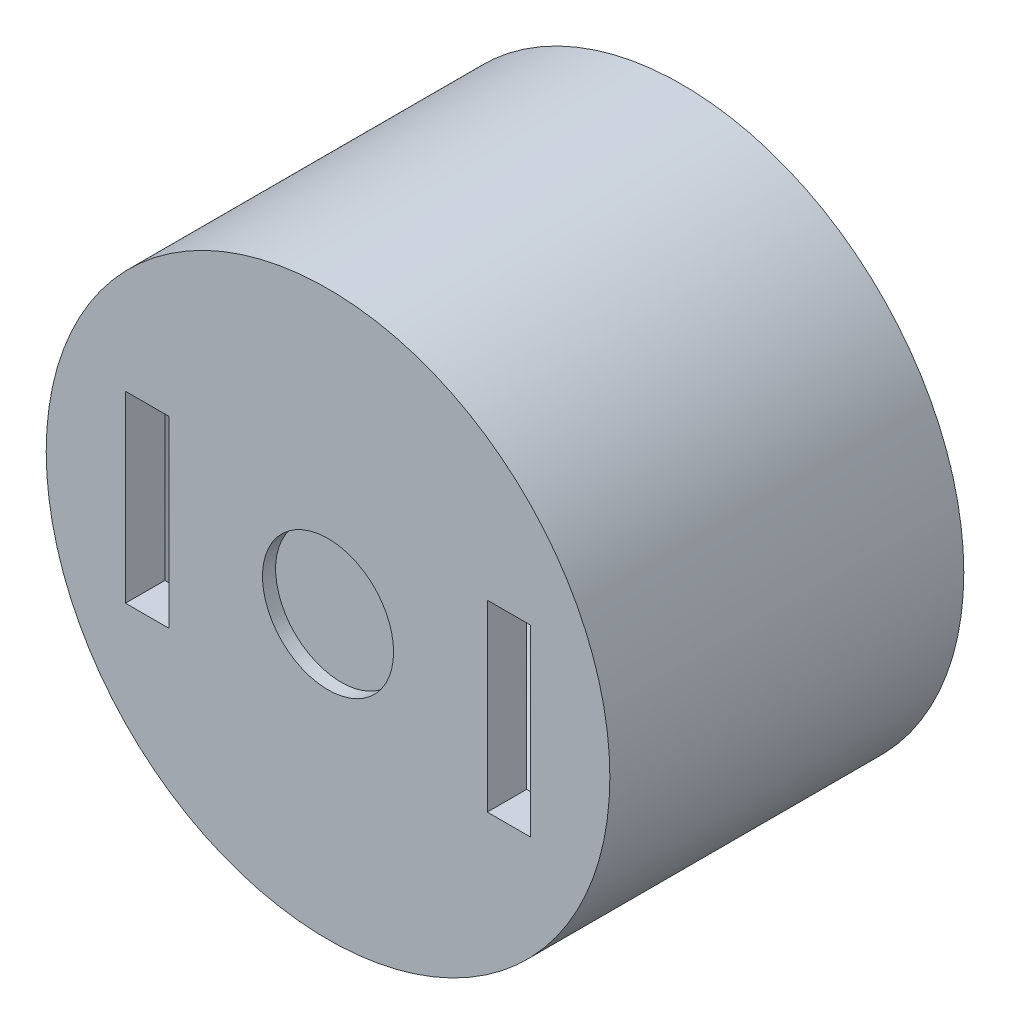
from build123d import *

# Parameters (mm, degrees)
SKETCH1_R           = 21.5
BOSS_EXTRUDE1_DEPTH = 27
SKETCH2_R           = 18.75
CUT_EXTRUDE2_DEPTH  = 24
SKETCH4_W           = 3.3
SKETCH4_H           = 14
CUT_EXTRUDE6_DEPTH  = 32
SKETCH7_R           = 5
CUT_EXTRUDE8_DEPTH  = 1


with BuildPart() as part:
    # Sketch1 → Boss-Extrude1 (new body)
    with BuildSketch(Plane.XY):
        Circle(SKETCH1_R)
    extrude(amount=BOSS_EXTRUDE1_DEPTH)

    # Sketch2 → Cut-Extrude2 (cut)
    with BuildSketch(Plane.XY):
        Circle(SKETCH2_R)
    extrude(amount=CUT_EXTRUDE2_DEPTH, mode=Mode.SUBTRACT)

    # Sketch4 → Cut-Extrude6 (cut)
    with BuildSketch(Plane.XY):
        with Locations((13.8, 0)):
            Rectangle(SKETCH4_W, SKETCH4_H)
        with Locations((-13.8, 0)):
            Rectangle(SKETCH4_W, SKETCH4_H)
    extrude(amount=CUT_EXTRUDE6_DEPTH, mode=Mode.SUBTRACT)

    # Sketch7 → Cut-Extrude8 (cut)
    with BuildSketch(Plane.XY.offset(27)):
        Circle(SKETCH7_R)
    extrude(amount=-CUT_EXTRUDE8_DEPTH, mode=Mode.SUBTRACT)


solid = part.part
